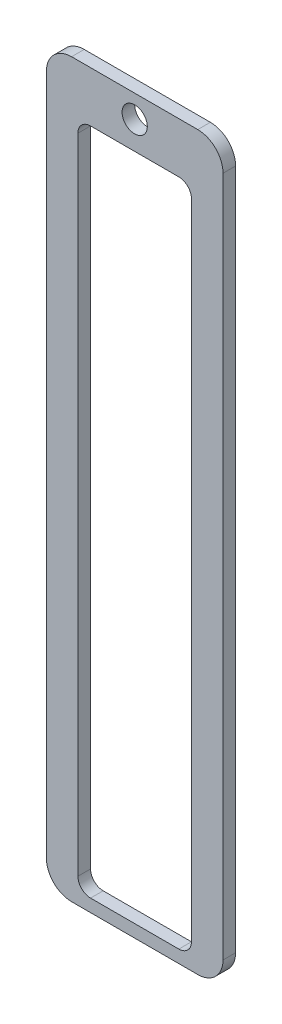
from build123d import *

# Parameters (mm, degrees)
BOSS_EXTRUDE3_DEPTH = 5
SKETCH6_R           = 5
CUT_EXTRUDE1_DEPTH  = 6


with BuildPart() as part:
    # Sketch4 → Boss-Extrude3 (new body)
    with BuildSketch(Plane.XY):
        with BuildLine():
            Line((-25, -290), (25, -290))
            ThreePointArc((25, -290), (32.071067812, -287.071067812), (35, -280))
            Line((35, -280), (35, -10))
            ThreePointArc((35, -10), (32.071067812, -2.928932188), (25, 0))
            Line((25, 0), (-25, 0))
            ThreePointArc((-25, 0), (-32.071067812, -2.928932188), (-35, -10))
            Line((-35, -10), (-35, -280))
            ThreePointArc((-35, -280), (-32.071067812, -287.071067812), (-25, -290))
        make_face()
    extrude(amount=BOSS_EXTRUDE3_DEPTH)

    # Sketch6 → Cut-Extrude1 (cut, through all)
    with BuildSketch(Plane.XY.offset(5)):
        with Locations((0, -9)):
            Circle(SKETCH6_R)
        with BuildLine():
            Line((-17.5, -20), (17.5, -20))
            ThreePointArc((17.5, -20), (21.035533906, -21.464466094), (22.5, -25))
            Line((22.5, -25), (22.5, -280))
            ThreePointArc((22.5, -280), (21.035533906, -283.535533906), (17.5, -285))
            Line((17.5, -285), (-17.5, -285))
            ThreePointArc((-17.5, -285), (-21.035533906, -283.535533906), (-22.5, -280))
            Line((-22.5, -280), (-22.5, -25))
            ThreePointArc((-22.5, -25), (-21.035533906, -21.464466094), (-17.5, -20))
        make_face()
    extrude(amount=-CUT_EXTRUDE1_DEPTH, mode=Mode.SUBTRACT)


solid = part.part
